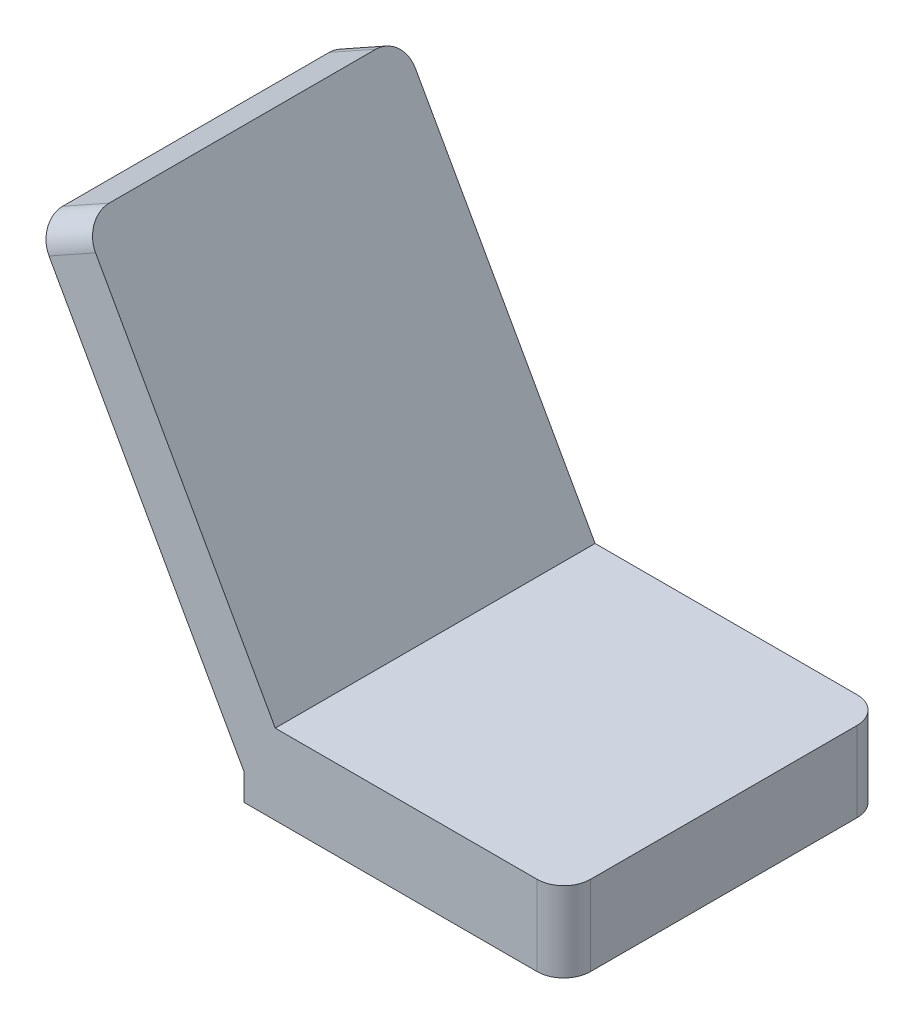
from build123d import *

# Parameters (mm, degrees)
EXTRUDE_THIN2_DEPTH = 60
SKETCH2_W           = 60
SKETCH2_H           = 60
BOSS_EXTRUDE1_DEPTH = 5
FILLET5_R           = 5
FILLET6_R           = 5
FILLET7_R           = 5
FILLET8_R           = 5


with BuildPart() as part:
    # Sketch1 → Extrude-Thin2 (new body)
    with BuildSketch(Plane.XY):
        Polygon((34.692024717, 0), (-25.307975283, 0), (-64.323670762, 69.841073204), (-55.593536612, 74.718035139), (-19.439751523, 10), (34.692024717, 10), align=None)
    extrude(amount=EXTRUDE_THIN2_DEPTH)

    # Sketch2 → Boss-Extrude1 (add)
    with BuildSketch(Plane.XZ):
        with Locations((4.692024717, 30)):
            Rectangle(SKETCH2_W, SKETCH2_H)
    extrude(amount=BOSS_EXTRUDE1_DEPTH)

    # Fillet5
    fillet5_edges = [part.edges().sort_by_distance(p)[0] for p in [
        (-59.958603687, 72.279554172, 60),
    ]]
    fillet(fillet5_edges, radius=FILLET5_R)

    # Fillet6
    fillet6_edges = [part.edges().sort_by_distance(p)[0] for p in [
        (34.692024717, 2.5, 60),
    ]]
    fillet(fillet6_edges, radius=FILLET6_R)

    # Fillet7
    fillet7_edges = [part.edges().sort_by_distance(p)[0] for p in [
        (34.692024717, 2.5, 0),
    ]]
    fillet(fillet7_edges, radius=FILLET7_R)

    # Fillet8
    fillet8_edges = [part.edges().sort_by_distance(p)[0] for p in [
        (-59.958603687, 72.279554172, 0),
    ]]
    fillet(fillet8_edges, radius=FILLET8_R)


solid = part.part
